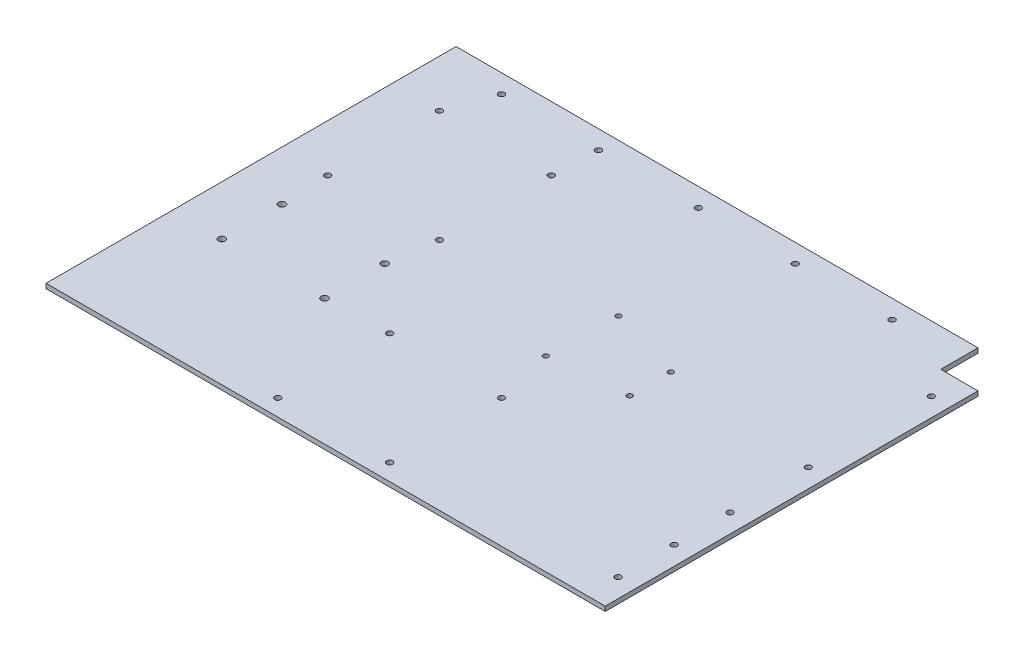
from build123d import *

# Parameters (mm, degrees)
BOSS_EXTRUDE1_DEPTH = 3.175
SKETCH5_R           = 2.032
CUT_EXTRUDE2_DEPTH  = 4.175
SKETCH6_R           = 2.032
CUT_EXTRUDE3_DEPTH  = 4.175
SKETCH7_R           = 1.778
CUT_EXTRUDE4_DEPTH  = 4.175
SKETCH10_R          = 2.347464755
CUT_EXTRUDE5_DEPTH  = 4.175
SKETCH11_R          = 2.032
CUT_EXTRUDE6_DEPTH  = 4.175


with BuildPart() as part:
    # Sketch2 → Boss-Extrude1 (new body)
    with BuildSketch(Plane(origin=(0, 0, 0), x_dir=(1, 0, 0), z_dir=(0, 1, 0))):
        Polygon((100.800624482, -73.920457953), (-280.199375518, -73.920457953), (-280.199375518, 205.479542047), (75.400624482, 205.479542047), (75.400624482, 180.079542047), (100.800624482, 180.079542047), align=None)
    extrude(amount=BOSS_EXTRUDE1_DEPTH)

    # Sketch5 → Cut-Extrude2 (cut, through all)
    with BuildSketch(Plane(origin=(0, 3.175, 0), x_dir=(1, 0, 0), z_dir=(0, 1, 0))):
        with Locations((-170.504769224, 192.779542047)):
            Circle(SKETCH5_R)
        with Locations((-102.399375518, 192.779542047)):
            Circle(SKETCH5_R)
        with Locations((-36.485198281, 192.779542047)):
            Circle(SKETCH5_R)
        with Locations((-236.544769224, 192.779542047)):
            Circle(SKETCH5_R)
        with Locations((29.554801719, 192.779542047)):
            Circle(SKETCH5_R)
    extrude(amount=-CUT_EXTRUDE2_DEPTH, mode=Mode.SUBTRACT)

    # Sketch6 → Cut-Extrude3 (cut, through all)
    with BuildSketch(Plane(origin=(0, 3.175, 0), x_dir=(1, 0, 0), z_dir=(0, 1, 0))):
        with Locations((88.100624482, 161.029542047)):
            Circle(SKETCH6_R)
        with Locations((88.100624482, 77.209542047)):
            Circle(SKETCH6_R)
        with Locations((88.100624482, 23.820250843)):
            Circle(SKETCH6_R)
        with Locations((88.100624482, -14.279749157)):
            Circle(SKETCH6_R)
        with Locations((88.100624482, -52.379749157)):
            Circle(SKETCH6_R)
    extrude(amount=-CUT_EXTRUDE3_DEPTH, mode=Mode.SUBTRACT)

    # Sketch7 → Cut-Extrude4 (cut, through all)
    with BuildSketch(Plane(origin=(0, 3.175, 0), x_dir=(1, 0, 0), z_dir=(0, 1, 0))):
        with Locations((-14.982897569, 86.532937611)):
            Circle(SKETCH7_R)
        with Locations((-14.982897569, 58.592937611)):
            Circle(SKETCH7_R)
        with Locations((-67.052897569, 53.512937611)):
            Circle(SKETCH7_R)
        with Locations((-65.782897569, 101.772937611)):
            Circle(SKETCH7_R)
    extrude(amount=-CUT_EXTRUDE4_DEPTH, mode=Mode.SUBTRACT)

    # Sketch10 → Cut-Extrude5 (cut, through all)
    with BuildSketch(Plane(origin=(0, 3.175, 0), x_dir=(1, 0, 0), z_dir=(0, 1, 0))):
        with Locations((-246.392967044, 53.079542047)):
            Circle(SKETCH10_R)
        with Locations((-176.426962748, 53.079542047)):
            Circle(SKETCH10_R)
        with Locations((-176.426962748, 12.08721928)):
            Circle(SKETCH10_R)
        with Locations((-246.392967044, 12.08721928)):
            Circle(SKETCH10_R)
    extrude(amount=-CUT_EXTRUDE5_DEPTH, mode=Mode.SUBTRACT)

    # Sketch11 → Cut-Extrude6 (cut, through all)
    with BuildSketch(Plane(origin=(0, 3.175, 0), x_dir=(1, 0, 0), z_dir=(0, 1, 0))):
        with Locations((-247.907630969, 161.84931011)):
            Circle(SKETCH11_R)
        with Locations((-171.707630969, 161.84931011)):
            Circle(SKETCH11_R)
        with Locations((-171.707630969, 85.64931011)):
            Circle(SKETCH11_R)
        with Locations((-247.907630969, 85.64931011)):
            Circle(SKETCH11_R)
        with Locations((-133.57300722, 13.606853626)):
            Circle(SKETCH11_R)
        with Locations((-57.37300722, 13.606853626)):
            Circle(SKETCH11_R)
        with Locations((-57.37300722, -62.593146374)):
            Circle(SKETCH11_R)
        with Locations((-133.57300722, -62.593146374)):
            Circle(SKETCH11_R)
    extrude(amount=-CUT_EXTRUDE6_DEPTH, mode=Mode.SUBTRACT)


solid = part.part
